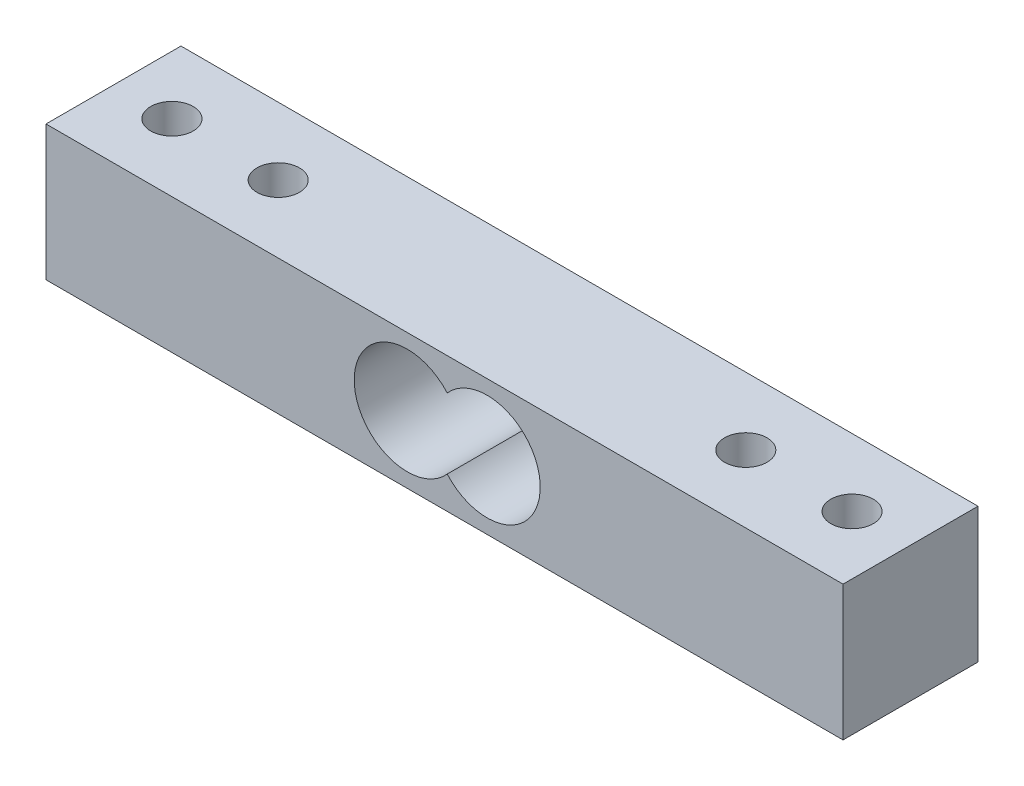
from build123d import *

# Parameters (mm, degrees)
SKETCH1_W           = 75
SKETCH1_H           = 12.7
SKETCH1_R           = 2
BOSS_EXTRUDE1_DEPTH = 12.7
SKETCH2_R           = 5
CUT_EXTRUDE1_DEPTH  = 12.7


with BuildPart() as part:
    # Sketch1 → Boss-Extrude1 (new body)
    with BuildSketch(Plane(origin=(0, 0, 0), x_dir=(1, 0, 0), z_dir=(0, 1, 0))):
        Rectangle(SKETCH1_W, SKETCH1_H)
        with Locations((-32, 0)):
            Circle(SKETCH1_R, mode=Mode.SUBTRACT)
        with Locations((-22, 0)):
            Circle(SKETCH1_R, mode=Mode.SUBTRACT)
        with Locations((22, 0)):
            Circle(SKETCH1_R, mode=Mode.SUBTRACT)
        with Locations((32, 0)):
            Circle(SKETCH1_R, mode=Mode.SUBTRACT)
    extrude(amount=BOSS_EXTRUDE1_DEPTH)

    # Sketch2 → Cut-Extrude1 (cut)
    with BuildSketch(Plane.XY.offset(6.35)):
        with Locations((-3.5, 6.35)):
            Circle(SKETCH2_R)
        with Locations((4.005771179, 6.35)):
            Circle(SKETCH2_R)
    extrude(amount=-CUT_EXTRUDE1_DEPTH, mode=Mode.SUBTRACT)


solid = part.part
